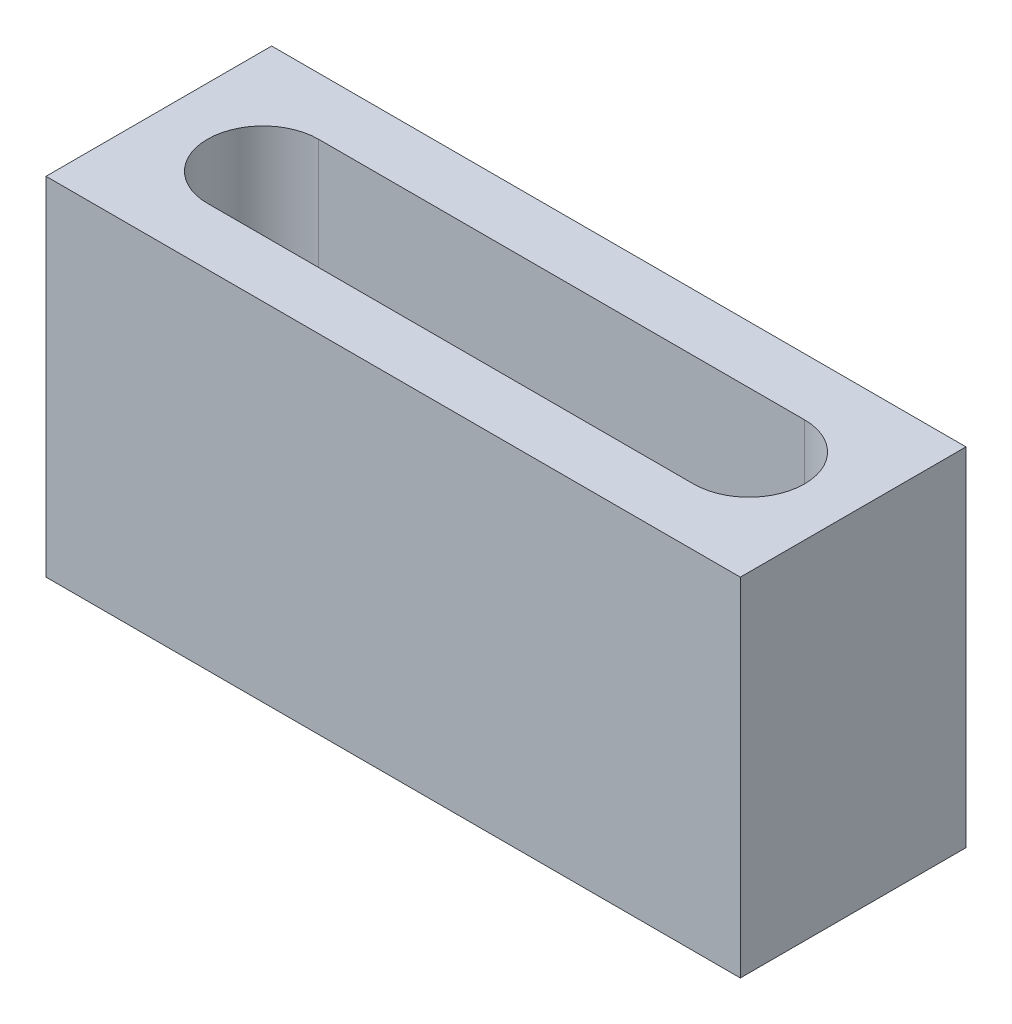
from build123d import *

# Parameters (mm, degrees)
SKETCH1_W           = 20
SKETCH1_H           = 6.5
BOSS_EXTRUDE1_DEPTH = 10


with BuildPart() as part:
    # Sketch1 → Boss-Extrude1 (new body)
    with BuildSketch(Plane(origin=(0, 0, 0), x_dir=(1, 0, 0), z_dir=(0, 1, 0))):
        Rectangle(SKETCH1_W, SKETCH1_H)
        with BuildLine():
            Line((-7, 1.6), (7, 1.6))
            ThreePointArc((7, 1.6), (8.6, 0), (7, -1.6))
            Line((7, -1.6), (-7, -1.6))
            ThreePointArc((-7, -1.6), (-8.6, 0), (-7, 1.6))
        make_face(mode=Mode.SUBTRACT)
    extrude(amount=BOSS_EXTRUDE1_DEPTH)


solid = part.part
